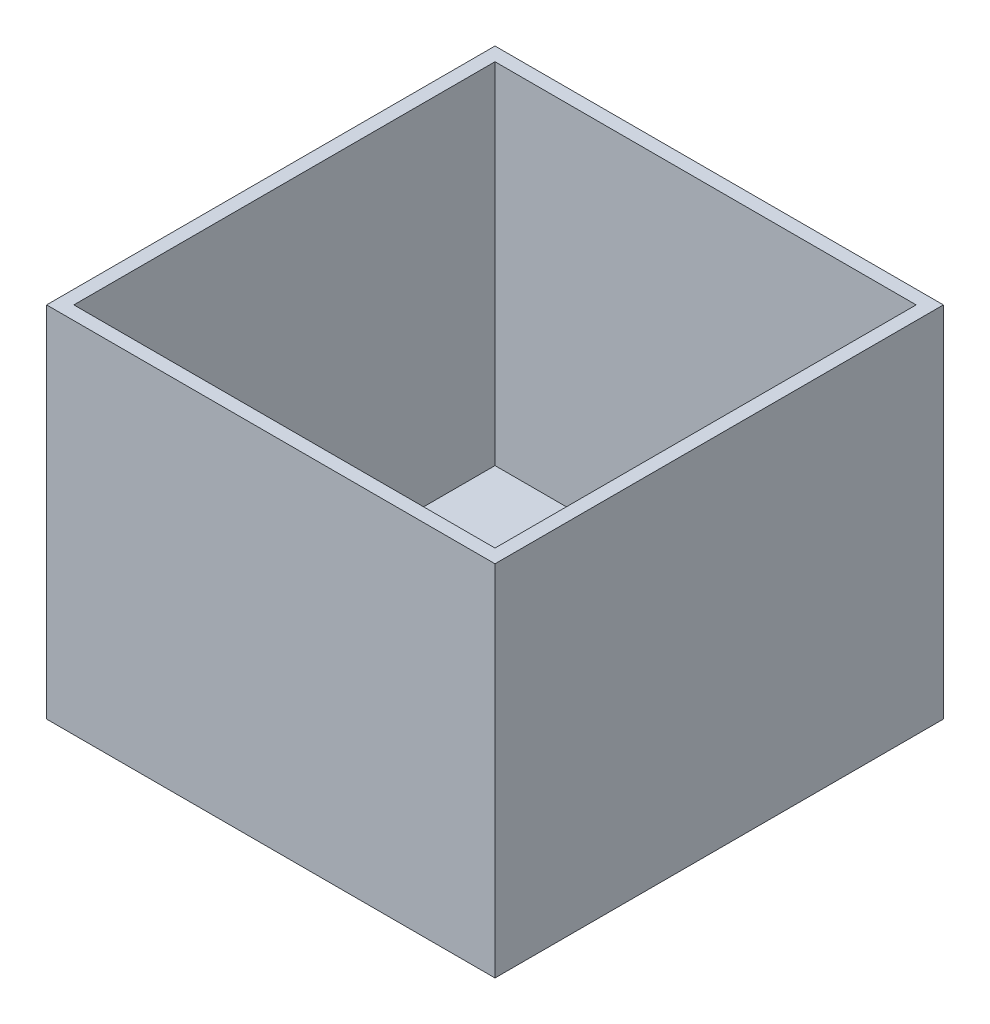
from build123d import *

# Parameters (mm, degrees)
SKETCH1_W           = 500
SKETCH1_H           = 500
BOSS_EXTRUDE1_DEPTH = 10
SKETCH2_W           = 500
SKETCH2_H           = 500
SKETCH2_W_2         = 469.614463364
SKETCH2_H_2         = 469.614463364
BOSS_EXTRUDE2_DEPTH = 400


with BuildPart() as part:
    # Sketch1 → Boss-Extrude1 (new body)
    with BuildSketch(Plane(origin=(0, 0, 0), x_dir=(1, 0, 0), z_dir=(0, 1, 0))):
        Rectangle(SKETCH1_W, SKETCH1_H)
    extrude(amount=BOSS_EXTRUDE1_DEPTH)

    # Sketch2 → Boss-Extrude2 (add)
    with BuildSketch(Plane(origin=(0, 0, 0), x_dir=(1, 0, 0), z_dir=(0, 1, 0))):
        Rectangle(SKETCH2_W, SKETCH2_H)
        Rectangle(SKETCH2_W_2, SKETCH2_H_2, mode=Mode.SUBTRACT)
    extrude(amount=BOSS_EXTRUDE2_DEPTH)


solid = part.part
